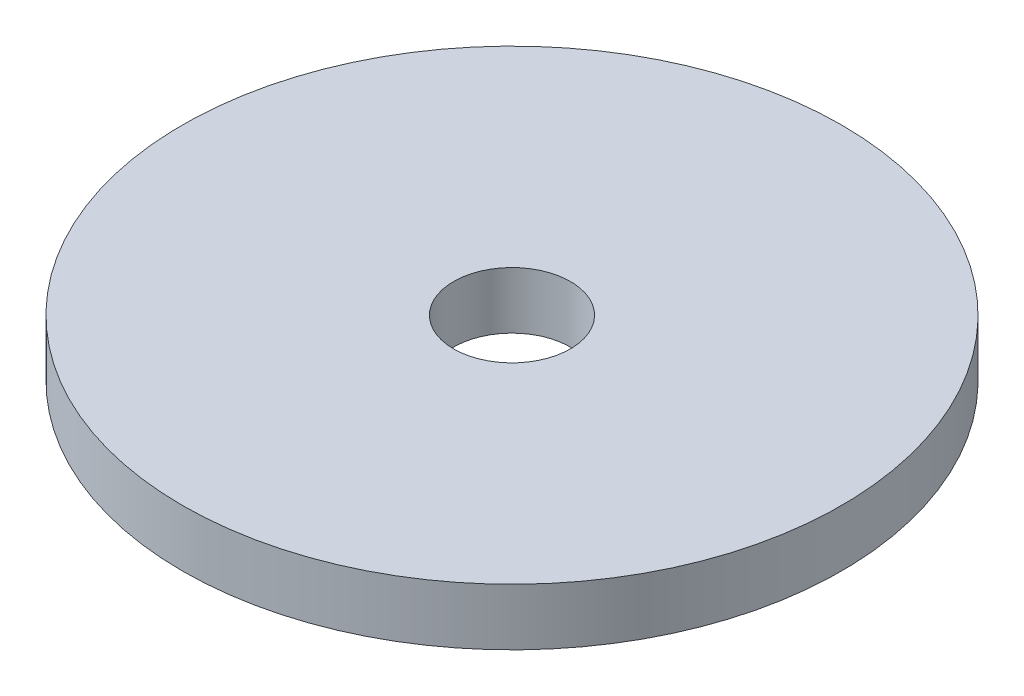
from build123d import *

# Parameters (mm, degrees)
SKETCH1_R                   = 18.415
BOSS_EXTRUDE1_DEPTH         = 3.175
F_1_4_CLEARANCE_HOLE1_D     = 6.5278
F_1_4_CLEARANCE_HOLE1_DEPTH = 25.4
F_1_4_CLEARANCE_HOLE1_TIP   = 1.961148974


with BuildPart() as part:
    # Sketch1 → Boss-Extrude1 (new body)
    with BuildSketch(Plane(origin=(0, 0, 0), x_dir=(1, 0, 0), z_dir=(0, 1, 0))):
        Circle(SKETCH1_R)
    extrude(amount=BOSS_EXTRUDE1_DEPTH)

    # 1/4 Clearance Hole1
    with Locations(Plane(origin=(0, 3.175, 0), x_dir=(1, 0, 0), z_dir=(0, 1, 0))):
        with Locations((0, 0)):
            Hole(F_1_4_CLEARANCE_HOLE1_D / 2, depth=F_1_4_CLEARANCE_HOLE1_DEPTH)
            with Locations((0, 0, -(F_1_4_CLEARANCE_HOLE1_DEPTH + F_1_4_CLEARANCE_HOLE1_TIP / 2))):  # 118° drill point
                Cone(0, F_1_4_CLEARANCE_HOLE1_D / 2, F_1_4_CLEARANCE_HOLE1_TIP, mode=Mode.SUBTRACT)


solid = part.part
